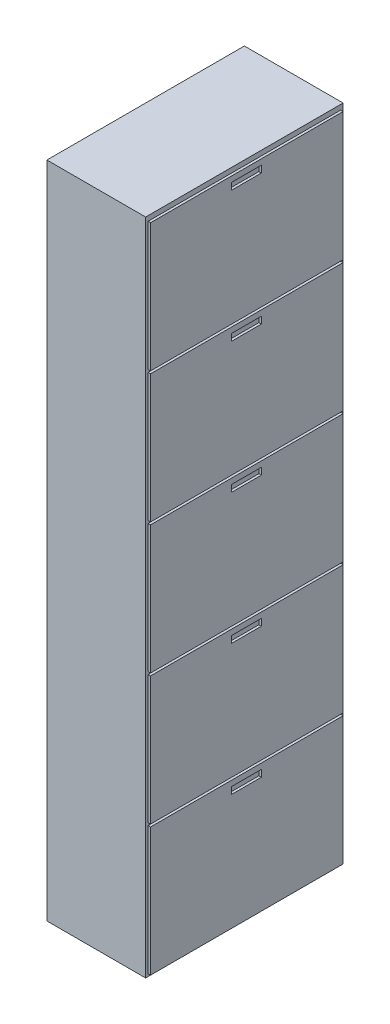
from build123d import *

# Parameters (mm, degrees)
SKETCH1_W           = 400
SKETCH1_H           = 2670
BOSS_EXTRUDE1_DEPTH = 800
SKETCH3_W           = 780
SKETCH3_H           = 520
SKETCH3_W_2         = 121.072841775
SKETCH3_H_2         = 27.505181151
BOSS_EXTRUDE3_DEPTH = 10


with BuildPart() as part:
    # Sketch1 → Boss-Extrude1 (new body)
    with BuildSketch(Plane.XY):
        with Locations((63.061970043, 2844.986327315)):
            Rectangle(SKETCH1_W, SKETCH1_H)
    extrude(amount=BOSS_EXTRUDE1_DEPTH)

    # Sketch3 → Boss-Extrude3 (add)
    with BuildSketch(Plane(origin=(263.061970043, 0, 0), x_dir=(0, 0, -1), z_dir=(1, 0, 0))):
        with Locations((-400, 2309.986327315)):
            Rectangle(SKETCH3_W, SKETCH3_H)
        with Locations((-401.761491339, 2533.738917891)):
            Rectangle(SKETCH3_W_2, SKETCH3_H_2, mode=Mode.SUBTRACT)
        with Locations((-400, 2839.986327315)):
            Rectangle(SKETCH3_W, SKETCH3_H)
        with Locations((-401.761491339, 3063.738917891)):
            Rectangle(SKETCH3_W_2, SKETCH3_H_2, mode=Mode.SUBTRACT)
        with Locations((-400, 3369.986327315)):
            Rectangle(SKETCH3_W, SKETCH3_H)
        with Locations((-401.761491339, 3593.738917891)):
            Rectangle(SKETCH3_W_2, SKETCH3_H_2, mode=Mode.SUBTRACT)
        with Locations((-400, 3899.986327315)):
            Rectangle(SKETCH3_W, SKETCH3_H)
        with Locations((-401.761491339, 4123.738917891)):
            Rectangle(SKETCH3_W_2, SKETCH3_H_2, mode=Mode.SUBTRACT)
        with Locations((-400, 1779.986327315)):
            Rectangle(SKETCH3_W, SKETCH3_H)
        with Locations((-401.761491339, 2003.738917891)):
            Rectangle(SKETCH3_W_2, SKETCH3_H_2, mode=Mode.SUBTRACT)
    extrude(amount=BOSS_EXTRUDE3_DEPTH)


solid = part.part
